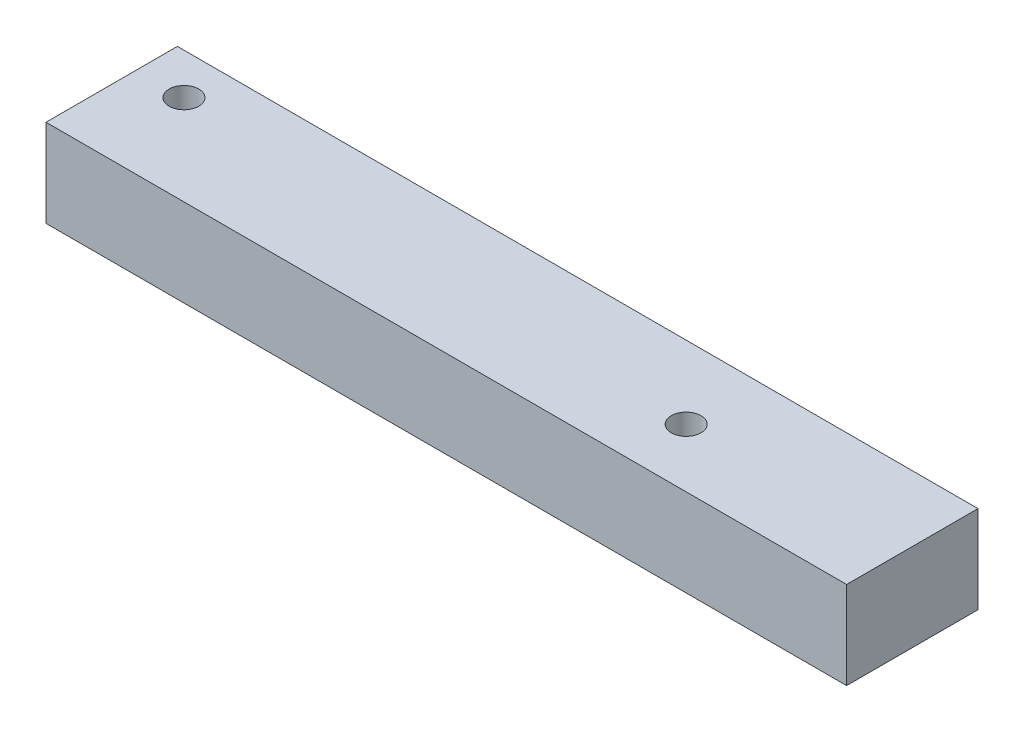
from build123d import *

# Parameters (mm, degrees)
SKETCH2_R           = 1.7
BOSS_EXTRUDE2_DEPTH = 10


with BuildPart() as part:
    # Sketch2 → Boss-Extrude2 (new body)
    with BuildSketch(Plane(origin=(0, 0, 0), x_dir=(1, 0, 0), z_dir=(0, 1, 0))):
        Polygon((-44.162144835, 83.28125), (47.234241277, 83.28125), (47.234241277, 68.28125), (14.234241277, 68.28125), (-44.162144835, 68.28125), align=None)
        with Locations((-38.719051078, 78.587953022)):
            Circle(SKETCH2_R, mode=Mode.SUBTRACT)
        with Locations((22.234241277, 74.963265867)):
            Circle(SKETCH2_R, mode=Mode.SUBTRACT)
    extrude(amount=BOSS_EXTRUDE2_DEPTH)


solid = part.part
